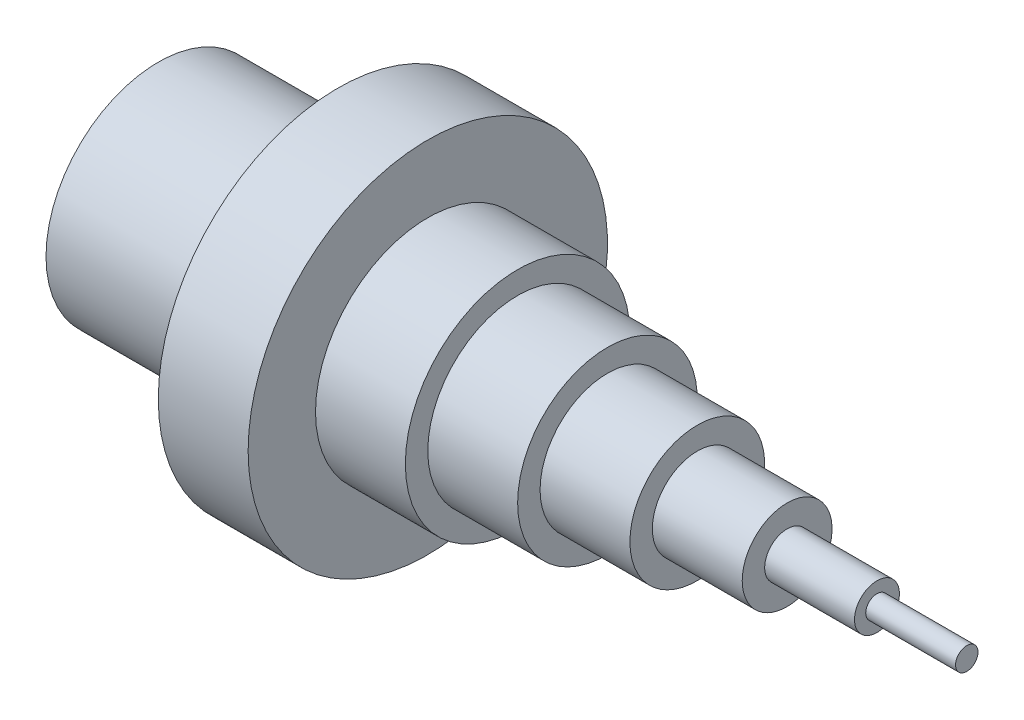
from build123d import *


with BuildPart() as part:
    # Sketch2 → Revolve6 (revolve)
    with BuildSketch(Plane.XY, mode=Mode.PRIVATE) as revolve6_sk:
        Polygon((1600, 50), (1600, 25), (1800, 25), (1800, 0), (400, 0), (400, 200), (0, 200), (0, 250), (400, 250), (400, 400), (600, 400), (600, 250), (800, 250), (800, 200), (1000, 200), (1000, 150), (1200, 150), (1200, 100), (1400, 100), (1400, 50), align=None)
    revolve(revolve6_sk.sketch.rotate(Axis((0, 0, 0), (1, 0, 0)), 90), axis=Axis((0, 0, 0), (1, 0, 0)))  # turned: the seam where the file's is


solid = part.part
